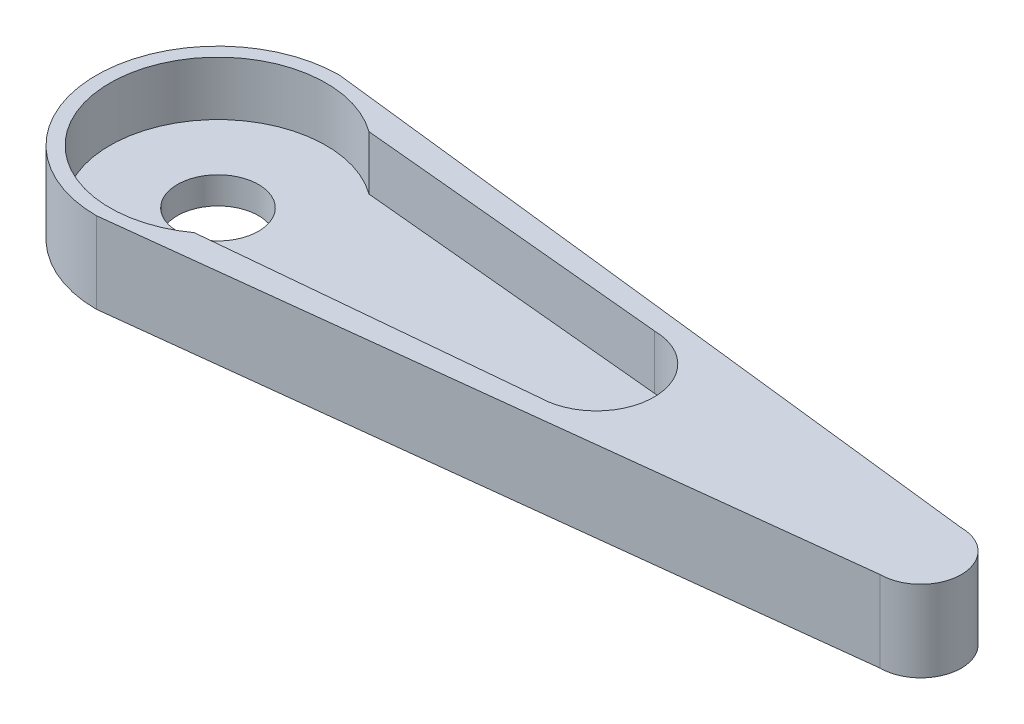
from build123d import *

# Parameters (mm, degrees)
SKETCH2_R           = 1.5
BOSS_EXTRUDE1_DEPTH = 1
BOSS_EXTRUDE2_DEPTH = 3


with BuildPart() as part:
    # Sketch2 → Boss-Extrude1 (new body)
    with BuildSketch(Plane(origin=(0, 0, 0), x_dir=(1, 0, 0), z_dir=(0, 1, 0))):
        with BuildLine():
            Line((-24.633695323, -3.234416395), (-12.961942578, -2.130426094))
            ThreePointArc((-12.961942578, -2.130426094), (-10.856533145, 0), (-12.961942578, 2.130426094))
            Line((-12.961942578, 2.130426094), (-24.633695323, 3.234416395))
            ThreePointArc((-24.633695323, 3.234416395), (-30.987107864, 0), (-24.633695323, -3.234416395))
        make_face()
        with Locations((-26.987107864, 0)):
            Circle(SKETCH2_R, mode=Mode.SUBTRACT)
    extrude(amount=BOSS_EXTRUDE1_DEPTH)

    # Sketch2_3 → Boss-Extrude2 (add)
    with BuildSketch(Plane(origin=(0, 0, 0), x_dir=(1, 0, 0), z_dir=(0, 1, 0))):
        with BuildLine():
            ThreePointArc((-26.987107864, 4.5), (-31.487107864, 0), (-26.987107864, -4.5))
            Line((-26.987107864, -4.5), (-0.987107864, -1.5))
            ThreePointArc((-0.987107864, -1.5), (0.512892136, 0), (-0.987107864, 1.5))
            Line((-0.987107864, 1.5), (-26.987107864, 4.5))
        make_face()
        with BuildLine():
            Line((-24.633695323, 3.234416395), (-12.961942578, 2.130426094))
            ThreePointArc((-12.961942578, 2.130426094), (-10.856533145, 0), (-12.961942578, -2.130426094))
            Line((-12.961942578, -2.130426094), (-24.633695323, -3.234416395))
            ThreePointArc((-24.633695323, -3.234416395), (-30.987107864, 0), (-24.633695323, 3.234416395))
        make_face(mode=Mode.SUBTRACT)
    extrude(amount=BOSS_EXTRUDE2_DEPTH)


solid = part.part
